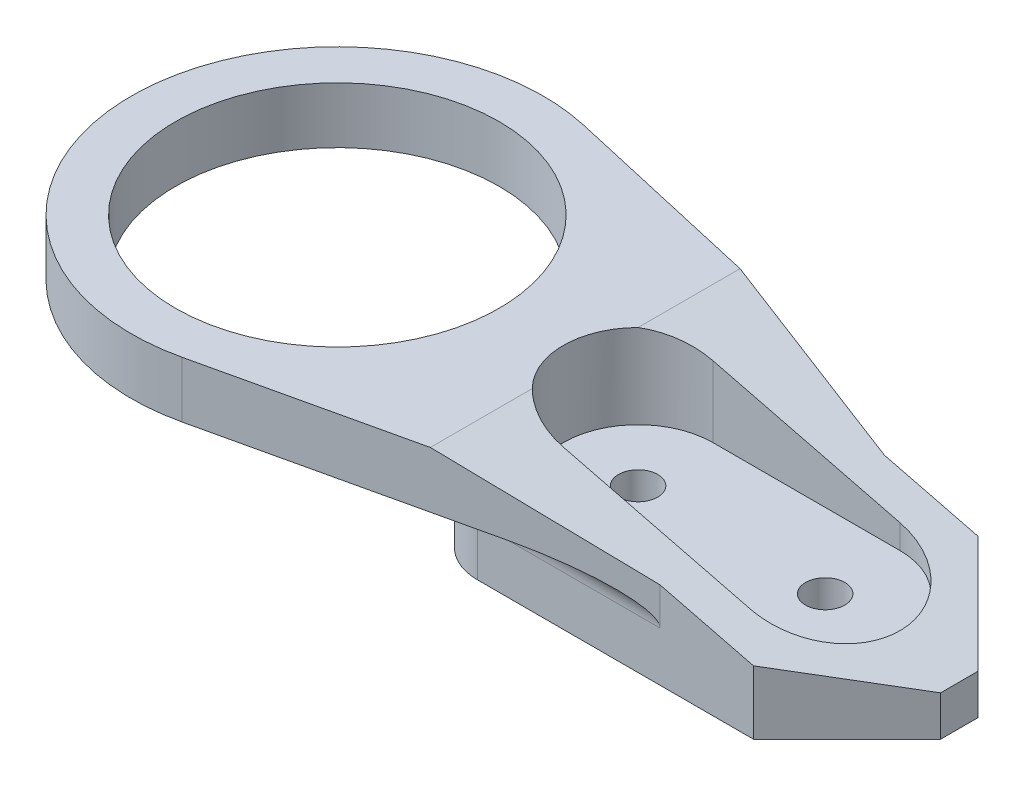
from build123d import *

# Parameters (mm, degrees)
SKETCH1_W           = 25
SKETCH1_H           = 7.15
BOSS_EXTRUDE1_DEPTH = 12
BOSS_EXTRUDE2_DEPTH = 3
CUT_EXTRUDE1_DEPTH  = 21
SKETCH4_R           = 8.65
CUT_EXTRUDE2_DEPTH  = 10
CHAMFER1_SIZE       = 5
CHAMFER1_SIZE2      = 20
CHAMFER2_SIZE       = 5
SKETCH6_R           = 1.05
CUT_EXTRUDE3_DEPTH  = 10
CUT_EXTRUDE4_DEPTH  = 4.5
FILLET1_R           = 3
FILLET2_R           = 1.5


with BuildPart() as part:
    # Sketch1 → Boss-Extrude1 (new body)
    with BuildSketch(Plane.XY):
        with Locations((12.5, 3.575)):
            Rectangle(SKETCH1_W, SKETCH1_H)
    extrude(amount=BOSS_EXTRUDE1_DEPTH)

    # Sketch2 → Boss-Extrude2 (add)
    with BuildSketch(Plane(origin=(0, 7.15, 0), x_dir=(1, 0, 0), z_dir=(0, 1, 0))):
        with BuildLine():
            Line((15, -12), (15, -6))
            Line((15, -6), (15, 0))
            Line((15, 0), (-5.804949202, 4.737516245))
            ThreePointArc((-5.804949202, 4.737516245), (-19.262380692, -6), (-5.804949202, -16.737516245))
            Line((-5.804949202, -16.737516245), (15, -12))
        make_face()
    extrude(amount=-BOSS_EXTRUDE2_DEPTH)

    # Sketch3 → Cut-Extrude1 (cut)
    with BuildSketch(Plane.XZ.offset(-4.15)):
        Polygon((2.25, 6), (2.25, 12), (0, 12), (0, 0), (2.25, 0), align=None)
    extrude(amount=CUT_EXTRUDE1_DEPTH, mode=Mode.SUBTRACT)

    # Sketch4 → Cut-Extrude2 (cut)
    with BuildSketch(Plane.XZ.offset(-4.15)):
        with Locations((-8.25, 6)):
            Circle(SKETCH4_R)
    extrude(amount=-CUT_EXTRUDE2_DEPTH, mode=Mode.SUBTRACT)

    # Chamfer1
    chamfer1_edges = [part.edges().sort_by_distance(p)[0] for p in [
        (25, 7.15, 6),
    ]]
    chamfer1_side = [part.faces().sort_by_distance(p)[0] for p in [
        (25, 3.575, 6),
    ]]
    chamfer(chamfer1_edges, length=CHAMFER1_SIZE, length2=CHAMFER1_SIZE2, reference=chamfer1_side[0])

    # Chamfer2
    chamfer2_edges = [part.edges().sort_by_distance(p)[0] for p in [
        (25, 1.075, 0),
        (25, 1.075, 12),
    ]]
    chamfer(chamfer2_edges, length=CHAMFER2_SIZE)

    # Sketch6 → Cut-Extrude3 (cut)
    with BuildSketch(Plane(origin=(0, 7.15, 0), x_dir=(1, 0, 0), z_dir=(0, 1, 0))):
        with Locations((7.829893366, -6)):
            Circle(SKETCH6_R)
        with Locations((17.829893366, -6)):
            Circle(SKETCH6_R)
    extrude(amount=-CUT_EXTRUDE3_DEPTH, mode=Mode.SUBTRACT)

    # Sketch7 → Cut-Extrude4 (cut)
    with BuildSketch(Plane(origin=(0, 7.15, 0), x_dir=(1, 0, 0), z_dir=(0, 1, 0))):
        with BuildLine():
            Line((7.829893366, -2), (17.829893366, -2))
            ThreePointArc((17.829893366, -2), (21.829893366, -6), (17.829893366, -10))
            Line((17.829893366, -10), (7.829893366, -10))
            ThreePointArc((7.829893366, -10), (3.829893366, -6), (7.829893366, -2))
        make_face()
    extrude(amount=-CUT_EXTRUDE4_DEPTH, mode=Mode.SUBTRACT)

    # Fillet1
    fillet1_edges = [part.edges().sort_by_distance(p)[0] for p in [
        (2.25, 2.075, 0),
        (2.25, 2.075, 12),
    ]]
    fillet(fillet1_edges, radius=FILLET1_R)

    # Fillet2
    fillet2_edges = [part.edges().sort_by_distance(p)[0] for p in [
        (2.25, 4.15, 6),
        (10.125, 4.15, 12),
        (3.128679656, 4.15, 11.121320344),
        (3.128679656, 4.15, 0.878679656),
        (10.125, 4.15, 0),
    ]]
    fillet(fillet2_edges, radius=FILLET2_R)


solid = part.part
